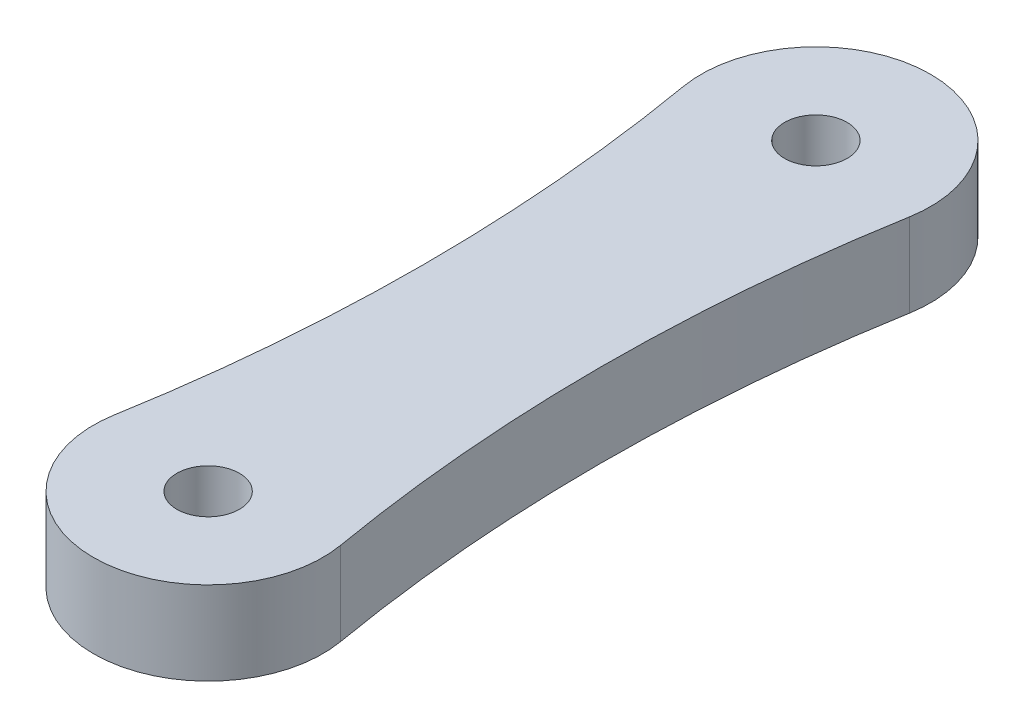
from build123d import *

# Parameters (mm, degrees)
SKETCH1_R           = 1.5
BOSS_EXTRUDE1_DEPTH = 4


with BuildPart() as part:
    # Sketch1 → Boss-Extrude1 (new body)
    with BuildSketch(Plane(origin=(0, 0, 0), x_dir=(1, 0, 0), z_dir=(0, 1, 0))):
        with BuildLine():
            ThreePointArc((-5.419681999, 0.93650789), (0, -5.5), (5.419681999, 0.93650789))
            ThreePointArc((5.419681999, 0.93650789), (4.25, 14.575), (5.419681999, 28.21349211))
            ThreePointArc((5.419681999, 28.21349211), (0, 34.65), (-5.419681999, 28.21349211))
            ThreePointArc((-5.419681999, 28.21349211), (-4.25, 14.575), (-5.419681999, 0.93650789))
        make_face()
        Circle(SKETCH1_R, mode=Mode.SUBTRACT)
        with Locations((0, 29.15)):
            Circle(SKETCH1_R, mode=Mode.SUBTRACT)
    extrude(amount=BOSS_EXTRUDE1_DEPTH)


solid = part.part
